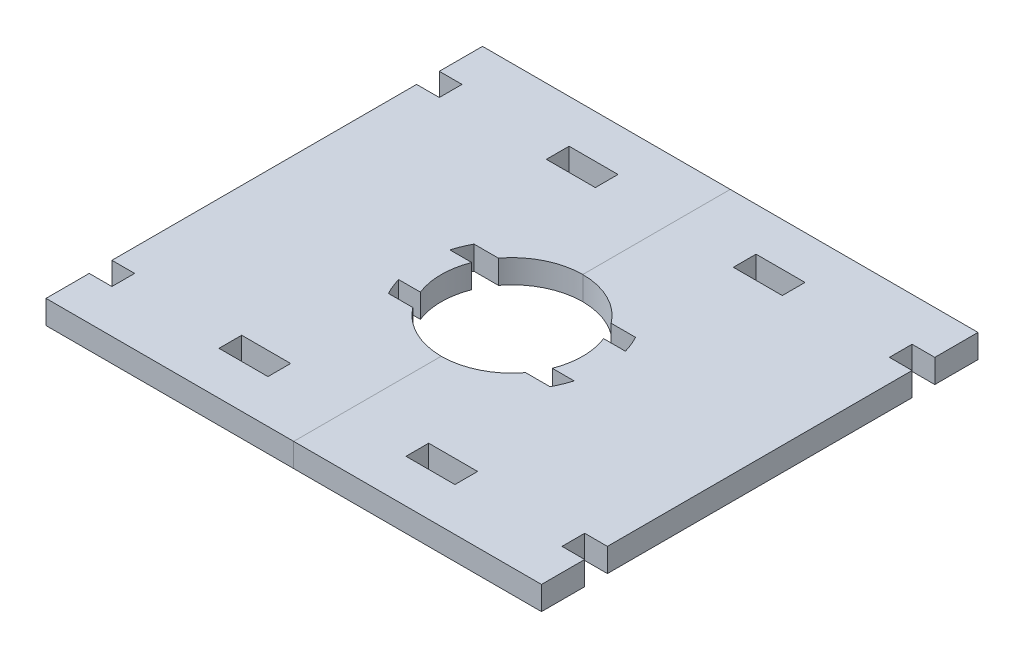
from build123d import *

# Parameters (mm, degrees)
SKETCH2_W               = 84
SKETCH2_H               = 74
BOSS_EXTRUDE1_DEPTH     = 4
SKETCH4_W               = 8.3
SKETCH4_H               = 3.85
SKETCH4_W_2             = 3.85
CUT_EXTRUDE2_DEPTH      = 1
CUT_EXTRUDE2_DEPTH_BACK = 5


with BuildPart() as part:
    # Sketch2 → Boss-Extrude1 (new body)
    with BuildSketch(Plane(origin=(0, 0, 0), x_dir=(1, 0, 0), z_dir=(0, 1, 0))):
        Rectangle(SKETCH2_W, SKETCH2_H)
        with BuildLine():
            ThreePointArc((11.183805256, 4.35), (12, 0), (11.183805256, -4.35))
            Line((11.183805256, -4.35), (14.877079687, -4.35))
            ThreePointArc((14.877079687, -4.35), (14.361878956, -5.829788405), (13.699908759, -7.25))
            Line((13.699908759, -7.25), (9.562295749, -7.25))
            ThreePointArc((9.562295749, -7.25), (0, -12), (-9.562295749, -7.25))
            Line((-9.562295749, -7.25), (-13.699908759, -7.25))
            ThreePointArc((-13.699908759, -7.25), (-14.361878956, -5.829788405), (-14.877079687, -4.35))
            Line((-14.877079687, -4.35), (-11.183805256, -4.35))
            ThreePointArc((-11.183805256, -4.35), (-12, 0), (-11.183805256, 4.35))
            Line((-11.183805256, 4.35), (-14.877079687, 4.35))
            ThreePointArc((-14.877079687, 4.35), (-14.361878956, 5.829788405), (-13.699908759, 7.25))
            Line((-13.699908759, 7.25), (-9.562295749, 7.25))
            ThreePointArc((-9.562295749, 7.25), (0, 12), (9.562295749, 7.25))
            Line((9.562295749, 7.25), (13.699908759, 7.25))
            ThreePointArc((13.699908759, 7.25), (14.361878956, 5.829788405), (14.877079687, 4.35))
            Line((14.877079687, 4.35), (11.183805256, 4.35))
        make_face(mode=Mode.SUBTRACT)
    extrude(amount=BOSS_EXTRUDE1_DEPTH)


with BuildPart() as body_2:
    # Split1: the piece on the far side of the plane
    add(part.part)
    split(bisect_by=Plane(origin=(0, 0, 0), x_dir=(0, 0, 1), z_dir=(1, 0, 0)), keep=Keep.BOTTOM)


with BuildPart() as part_1:
    add(part.part)

    # Split1
    split(bisect_by=Plane(origin=(0, 0, 0), x_dir=(0, 0, 1), z_dir=(1, 0, 0)), keep=Keep.TOP)


with BuildPart() as cut_extrude2_tool:
    # Sketch4 → Cut-Extrude2 (new body, two sides)
    with BuildSketch(Plane(origin=(0, 4, 0), x_dir=(1, 0, 0), z_dir=(0, 1, 0))) as cut_extrude2_sk:
        with Locations((-15.85, -27.75)):
            Rectangle(SKETCH4_W, SKETCH4_H)
        with Locations((-40.075, -27.75)):
            Rectangle(SKETCH4_W_2, SKETCH4_H)
        with Locations((40.075, -27.75)):
            Rectangle(SKETCH4_W_2, SKETCH4_H)
        with Locations((15.85, -27.75)):
            Rectangle(SKETCH4_W, SKETCH4_H)
        with Locations((15.85, 27.75)):
            Rectangle(SKETCH4_W, SKETCH4_H)
        with Locations((40.075, 27.75)):
            Rectangle(SKETCH4_W_2, SKETCH4_H)
        with Locations((-40.075, 27.75)):
            Rectangle(SKETCH4_W_2, SKETCH4_H)
        with Locations((-15.85, 27.75)):
            Rectangle(SKETCH4_W, SKETCH4_H)
    extrude(amount=CUT_EXTRUDE2_DEPTH)
    extrude(cut_extrude2_sk.sketch, amount=-CUT_EXTRUDE2_DEPTH_BACK)


with BuildPart() as part_2:
    add(part_1.part)

    # Cut-Extrude2: cut by cut_extrude2_tool
    add(cut_extrude2_tool.part, mode=Mode.SUBTRACT)


with BuildPart() as body_2_1:
    add(body_2.part)

    # Cut-Extrude2: cut by cut_extrude2_tool
    add(cut_extrude2_tool.part, mode=Mode.SUBTRACT)


solid = Compound([part_2.part, body_2_1.part])
